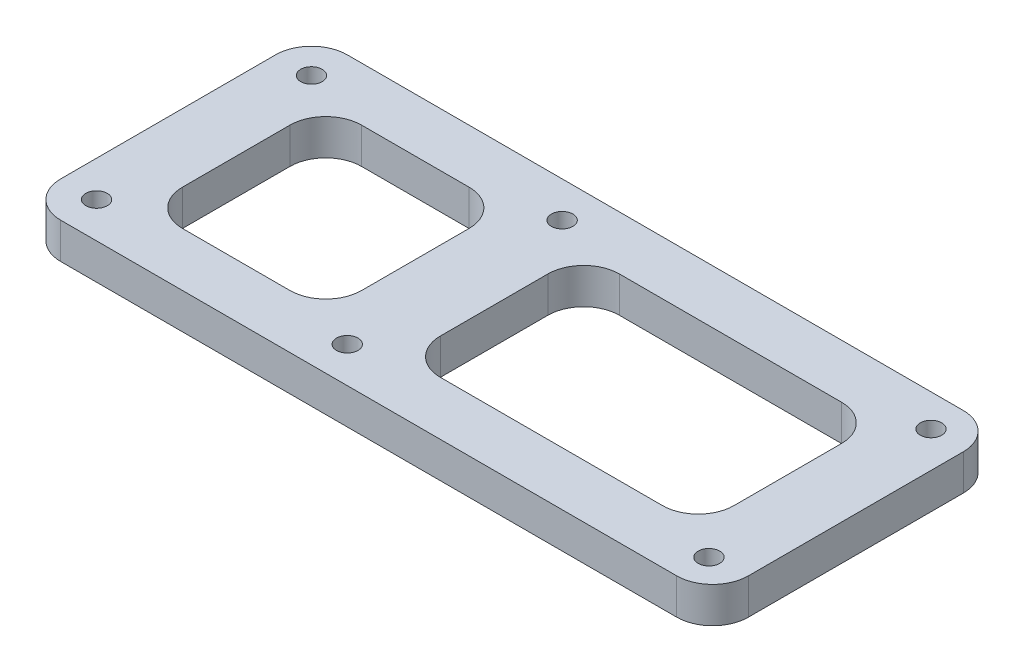
from build123d import *

# Parameters (mm, degrees)
SKETCH1_W           = 96
SKETCH1_H           = 40
SKETCH1_R           = 1.5
SKETCH1_W_2         = 25
SKETCH1_H_2         = 25
SKETCH1_W_3         = 41
BOSS_EXTRUDE1_DEPTH = 5
FILLET1_R           = 5


with BuildPart() as part:
    # Sketch1 → Boss-Extrude1 (new body)
    with BuildSketch(Plane(origin=(0, 0, 0), x_dir=(1, 0, 0), z_dir=(0, 1, 0))):
        with Locations((8, 0)):
            Rectangle(SKETCH1_W, SKETCH1_H)
        with Locations((-35, 15)):
            Circle(SKETCH1_R, mode=Mode.SUBTRACT)
        with Locations((0, 15)):
            Circle(SKETCH1_R, mode=Mode.SUBTRACT)
        with Locations((50.997548961, -15.5)):
            Circle(SKETCH1_R, mode=Mode.SUBTRACT)
        with Locations((50.997548961, 15.5)):
            Circle(SKETCH1_R, mode=Mode.SUBTRACT)
        with Locations((-35, -15)):
            Circle(SKETCH1_R, mode=Mode.SUBTRACT)
        with Locations((0, -15)):
            Circle(SKETCH1_R, mode=Mode.SUBTRACT)
        with Locations((-18, 0)):
            Rectangle(SKETCH1_W_2, SKETCH1_H_2, mode=Mode.SUBTRACT)
        with Locations((26, 0)):
            Rectangle(SKETCH1_W_3, SKETCH1_H_2, mode=Mode.SUBTRACT)
    extrude(amount=BOSS_EXTRUDE1_DEPTH)

    # Fillet1
    fillet1_edges = [part.edges().sort_by_distance(p)[0] for p in [
        (-5.5, 2.5, 12.5),
        (-5.5, 2.5, -12.5),
        (-30.5, 2.5, -12.5),
        (-30.5, 2.5, 12.5),
        (-40, 2.5, 20),
        (-40, 2.5, -20),
        (56, 2.5, -20),
        (56, 2.5, 20),
        (46.5, 2.5, 12.5),
        (46.5, 2.5, -12.5),
        (5.5, 2.5, -12.5),
        (5.5, 2.5, 12.5),
    ]]
    fillet(fillet1_edges, radius=FILLET1_R)


solid = part.part
